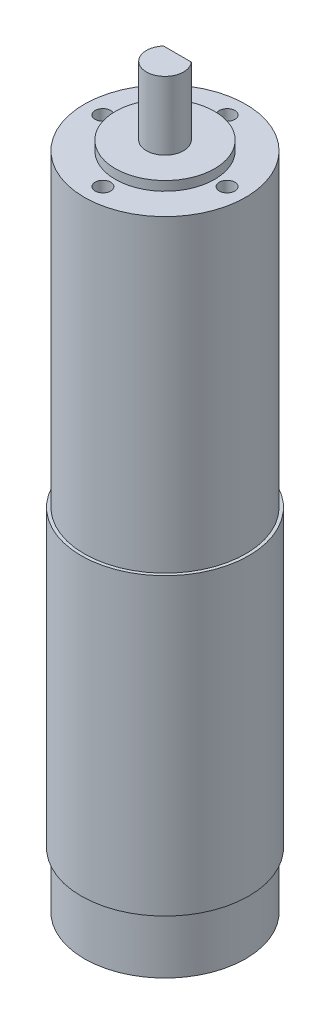
from build123d import *

# Parameters (mm, degrees)
SKETCH1_R           = 27
BOSS_EXTRUDE1_DEPTH = 95
SKETCH2_R           = 26
BOSS_EXTRUDE2_DEPTH = 99.5
SKETCH3_R           = 16
BOSS_EXTRUDE3_DEPTH = 3
SKETCH4_R           = 6
BOSS_EXTRUDE4_DEPTH = 22
CUT_EXTRUDE1_DEPTH  = 15
SKETCH6_R           = 2.5
CUT_EXTRUDE2_DEPTH  = 10
SKETCH7_R           = 26
BOSS_EXTRUDE5_DEPTH = 18


with BuildPart() as part:
    # Sketch1 → Boss-Extrude1 (new body)
    with BuildSketch(Plane(origin=(0, 0, 0), x_dir=(1, 0, 0), z_dir=(0, 1, 0))):
        Circle(SKETCH1_R)
    extrude(amount=BOSS_EXTRUDE1_DEPTH)

    # Sketch2 → Boss-Extrude2 (add)
    with BuildSketch(Plane(origin=(0, 95, 0), x_dir=(1, 0, 0), z_dir=(0, 1, 0))):
        Circle(SKETCH2_R)
    extrude(amount=BOSS_EXTRUDE2_DEPTH)

    # Sketch3 → Boss-Extrude3 (add)
    with BuildSketch(Plane(origin=(0, 194.5, 0), x_dir=(1, 0, 0), z_dir=(0, 1, 0))):
        Circle(SKETCH3_R)
    extrude(amount=BOSS_EXTRUDE3_DEPTH)

    # Sketch4 → Boss-Extrude4 (add)
    with BuildSketch(Plane(origin=(0, 197.5, 0), x_dir=(1, 0, 0), z_dir=(0, 1, 0))):
        Circle(SKETCH4_R)
    extrude(amount=BOSS_EXTRUDE4_DEPTH)

    # Sketch5 → Cut-Extrude1 (cut)
    with BuildSketch(Plane(origin=(0, 219.5, 0), x_dir=(1, 0, 0), z_dir=(0, 1, 0))):
        with BuildLine():
            Line((-4.472135955, 4), (4.472135955, 4))
            ThreePointArc((4.472135955, 4), (0, 6), (-4.472135955, 4))
        make_face()
    extrude(amount=-CUT_EXTRUDE1_DEPTH, mode=Mode.SUBTRACT)

    # Sketch6 → Cut-Extrude2 (cut)
    with BuildSketch(Plane(origin=(0, 194.5, 0), x_dir=(1, 0, 0), z_dir=(0, 1, 0))):
        with Locations((0, 20)):
            Circle(SKETCH6_R)
        with Locations((-20, 0)):
            Circle(SKETCH6_R)
        with Locations((0, -20)):
            Circle(SKETCH6_R)
        with Locations((20, 0)):
            Circle(SKETCH6_R)
    extrude(amount=-CUT_EXTRUDE2_DEPTH, mode=Mode.SUBTRACT)

    # Sketch7 → Boss-Extrude5 (add)
    with BuildSketch(Plane.XZ):
        Circle(SKETCH7_R)
    extrude(amount=BOSS_EXTRUDE5_DEPTH)


solid = part.part
